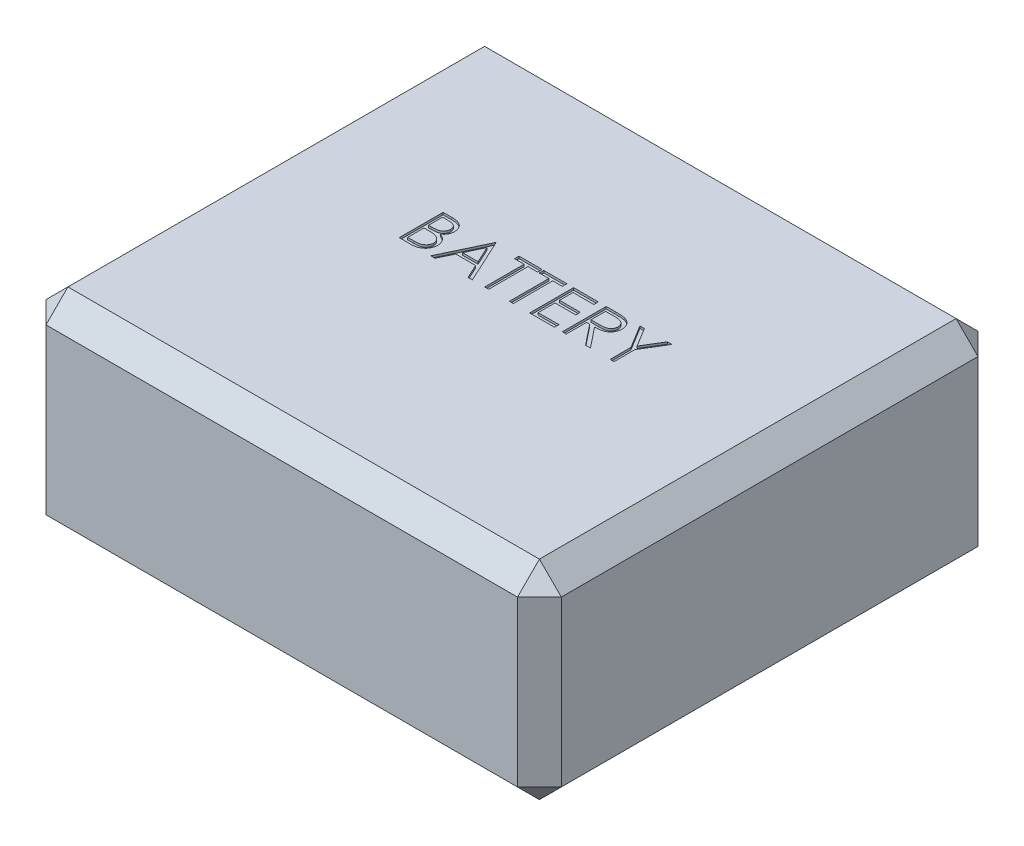
from build123d import *

# Parameters (mm, degrees)
SKETCH1_W           = 235
SKETCH1_H           = 210
BOSS_EXTRUDE1_DEPTH = 95
CUT_EXTRUDE1_DEPTH  = 1
CHAMFER1_SIZE       = 10


with BuildPart() as part:
    # Sketch1 → Boss-Extrude1 (new body)
    with BuildSketch(Plane(origin=(0, 0, 0), x_dir=(1, 0, 0), z_dir=(0, 1, 0))):
        with Locations((117.5, 105)):
            Rectangle(SKETCH1_W, SKETCH1_H)
    extrude(amount=BOSS_EXTRUDE1_DEPTH)

    # Sketch2 → Cut-Extrude1 (cut)
    with BuildSketch(Plane(origin=(0, 95, 0), x_dir=(1, 0, 0), z_dir=(0, 1, 0))):
        with BuildLine():
            Line((66.08974359, 125), (69.991987179, 125))
            add(Edge.make_bspline(
                [(69.991987179, 125), (70.183007055, 124.998995712), (70.553251114, 124.997049152), (71.091647924, 124.966859831), (71.595926842, 124.925696003), (72.066234113, 124.860381188), (72.502352412, 124.781571033), (72.905596054, 124.686132084), (73.274682752, 124.571694292), (73.71532696, 124.389715542), (74.217730737, 124.119297437), (74.761721552, 123.719705636), (75.226888634, 123.230948704), (75.627953304, 122.679619244), (75.946816845, 122.07312912), (76.177498544, 121.425933755), (76.323543546, 120.746380945), (76.33856317, 120.279848499), (76.346153846, 120.044070513)],
                knots=[0, 0, 0, 0, 1.001505555, 1.941167018, 2.826882275, 3.653841531, 4.429895133, 5.150066043, 5.825578002, 6.45369114, 7.647487171, 8.808567382, 9.977351308, 11.170798116, 12.373658725, 13.556498008, 14.765093433, 16, 16, 16, 16], degree=3))
            add(Edge.make_bspline(
                [(76.346153846, 120.044070513), (76.339906884, 119.823198766), (76.327631013, 119.389164955), (76.210243817, 118.754341473), (76.026468569, 118.150048794), (75.771010002, 117.578492306), (75.438998595, 117.052585945), (75.045522489, 116.568087282), (74.570797903, 116.145509813), (74.215122246, 115.909264656), (74.034455128, 115.789262821)],
                knots=[0, 0, 0, 0, 1.044552857, 2.05264487, 3.044412934, 4.028983338, 5.005914585, 5.980388656, 6.974128949, 8, 8, 8, 8], degree=3))
            add(Edge.make_bspline(
                [(74.034455128, 115.789262821), (74.261657572, 115.702034255), (74.696352128, 115.535144401), (75.294557913, 115.240084607), (75.809957028, 114.919158262), (76.246512148, 114.568690547), (76.619870176, 114.190925914), (76.945886985, 113.780325261), (77.224066266, 113.331532359), (77.462425829, 112.849226443), (77.64841872, 112.338332338), (77.787709602, 111.803642189), (77.867523598, 111.247073302), (77.878881548, 110.868299705), (77.884615385, 110.677083333)],
                knots=[0, 0, 0, 0, 1.27268992, 2.434971085, 3.483601985, 4.442670788, 5.356604649, 6.2567628, 7.179492994, 8.113709626, 9.066344395, 10.018646069, 10.999752585, 12, 12, 12, 12], degree=3))
            add(Edge.make_bspline(
                [(77.884615385, 110.677083333), (77.879033407, 110.481844064), (77.868050711, 110.097705332), (77.7870223, 109.533390277), (77.649827403, 108.994104868), (77.460849424, 108.476360967), (77.214207626, 107.981160199), (76.91404783, 107.507941547), (76.556153181, 107.061459658), (76.15579393, 106.63675324), (75.702867384, 106.25488017), (75.214205927, 105.914790417), (74.683655528, 105.635098634), (74.119929848, 105.40014994), (73.516705184, 105.220680234), (72.876690285, 105.095122669), (72.200437132, 105.010522457), (71.736381411, 105.003567001), (71.498397436, 105)],
                knots=[0, 0, 0, 0, 0.978564426, 1.925352924, 2.850884081, 3.763762016, 4.682927383, 5.618979971, 6.567305752, 7.547517671, 8.540179244, 9.531824382, 10.526200242, 11.540722885, 12.589160233, 13.674978461, 14.80764778, 16, 16, 16, 16], degree=3))
            Line((71.498397436, 105), (66.08974359, 105))
            Line((66.08974359, 105), (66.08974359, 125))
        make_face()
        with BuildLine():
            Line((67.884615385, 122.948717949), (67.884615385, 116.538461538))
            Line((67.884615385, 116.538461538), (69.090544872, 116.538461538))
            add(Edge.make_bspline(
                [(69.090544872, 116.538461538), (69.266823702, 116.540746813), (69.607430327, 116.545162428), (70.100686879, 116.557811097), (70.558544125, 116.593228488), (70.980211743, 116.6286357), (71.365025708, 116.686204772), (71.712133488, 116.754731189), (72.026982614, 116.827204933), (72.390065731, 116.950459143), (72.801911151, 117.132617287), (73.24095746, 117.415313494), (73.628011572, 117.752024083), (73.954852645, 118.140543865), (74.222346762, 118.568350641), (74.40813942, 119.028618529), (74.534123901, 119.509876427), (74.545504081, 119.840266443), (74.551282051, 120.008012821)],
                knots=[0, 0, 0, 0, 1.156816544, 2.235205308, 3.236616184, 4.169592532, 5.011045266, 5.787822928, 6.49130361, 7.128639758, 8.301311294, 9.436451833, 10.541879658, 11.654887649, 12.756523258, 13.837046038, 14.901820046, 16, 16, 16, 16], degree=3))
            add(Edge.make_bspline(
                [(74.551282051, 120.008012821), (74.548275307, 120.119017229), (74.542377251, 120.336764498), (74.494072665, 120.654189379), (74.411972239, 120.952725108), (74.306519135, 121.236462881), (74.159155199, 121.496530597), (73.985649695, 121.741920286), (73.776017179, 121.964275249), (73.537403964, 122.172100954), (73.263068976, 122.356355398), (72.95317588, 122.517731188), (72.603532011, 122.647678483), (72.220029982, 122.761485069), (71.796766625, 122.841418176), (71.33862632, 122.908008963), (70.841856497, 122.941910346), (70.498170197, 122.946398134), (70.320512821, 122.948717949)],
                knots=[0, 0, 0, 0, 0.91205012, 1.789085906, 2.630437955, 3.453916878, 4.269457761, 5.079663411, 5.91843418, 6.774407191, 7.675494373, 8.627863946, 9.638891023, 10.736472738, 11.911756761, 13.175263542, 14.539845004, 16, 16, 16, 16], degree=3))
            Line((70.320512821, 122.948717949), (67.884615385, 122.948717949))
        make_face(mode=Mode.SUBTRACT)
        with BuildLine():
            Line((67.884615385, 114.487179487), (67.884615385, 107.051282051))
            Line((67.884615385, 107.051282051), (70.440705128, 107.051282051))
            add(Edge.make_bspline(
                [(70.440705128, 107.051282051), (70.623670419, 107.053474894), (70.976311897, 107.057701308), (71.485461783, 107.071498763), (71.957365233, 107.102883195), (72.389868866, 107.15228805), (72.787642881, 107.205879188), (73.14591547, 107.277943651), (73.467590861, 107.36050914), (73.840586905, 107.488132981), (74.260606953, 107.686398529), (74.713240418, 107.985336966), (75.11567595, 108.341470153), (75.457420288, 108.753646805), (75.737494509, 109.201825816), (75.941239966, 109.676942102), (76.066902005, 110.171145116), (76.082114401, 110.508097759), (76.08974359, 110.677083333)],
                knots=[0, 0, 0, 0, 1.160039823, 2.235823828, 3.228722157, 4.157150951, 4.99529583, 5.772374946, 6.472645482, 7.099169577, 8.269452708, 9.405989375, 10.527446681, 11.663510218, 12.788923519, 13.866172445, 14.929861265, 16, 16, 16, 16], degree=3))
            add(Edge.make_bspline(
                [(76.08974359, 110.677083333), (76.088165851, 110.782759565), (76.085035822, 110.992407461), (76.037832308, 111.300497856), (75.969181623, 111.598931418), (75.880430572, 111.888518506), (75.751176475, 112.164023514), (75.600281932, 112.430895283), (75.423359637, 112.689486594), (75.147678689, 113.016413756), (74.74669592, 113.393082402), (74.176942918, 113.761868129), (73.529101215, 114.059284169), (73.059229827, 114.185566891), (72.81650641, 114.250801282)],
                knots=[0, 0, 0, 0, 0.723448775, 1.435228256, 2.130040452, 2.821711965, 3.505591119, 4.210454504, 4.921174351, 5.648778258, 7.137944449, 8.670945889, 10.280296675, 12, 12, 12, 12], degree=3))
            add(Edge.make_bspline(
                [(72.81650641, 114.250801282), (72.719197291, 114.270544619), (72.508211049, 114.313352246), (72.164167732, 114.358539122), (71.771391339, 114.398796607), (71.328974897, 114.428574651), (70.836358662, 114.4593549), (70.292490556, 114.471325306), (69.699591615, 114.485606793), (69.28820663, 114.486641845), (69.074519231, 114.487179487)],
                knots=[0, 0, 0, 0, 0.634451884, 1.375622551, 2.216452059, 3.157844607, 4.20941857, 5.370758133, 6.634282058, 8, 8, 8, 8], degree=3))
            Line((69.074519231, 114.487179487), (67.884615385, 114.487179487))
        make_face(mode=Mode.SUBTRACT)
        Polygon((90.192307692, 125), (99.423076923, 105), (97.471955128, 105), (94.515224359, 111.41025641), (85.448717949, 111.41025641), (82.411858974, 105), (80.448717949, 105), (89.935897436, 125), align=None)
        Polygon((90.044070513, 121.09775641), (86.426282051, 113.461538462), (93.569711538, 113.461538462), align=None, mode=Mode.SUBTRACT)
        Polygon((100.705128205, 122.948717949), (100.705128205, 125), (111.217948718, 125), (111.217948718, 122.948717949), (106.858974359, 122.948717949), (106.858974359, 105), (105.064102564, 105), (105.064102564, 122.948717949), align=None)
        Polygon((111.987179487, 122.948717949), (111.987179487, 125), (122.5, 125), (122.5, 122.948717949), (118.141025641, 122.948717949), (118.141025641, 105), (116.346153846, 105), (116.346153846, 122.948717949), align=None)
        Polygon((125.576923077, 125), (136.858974359, 125), (136.858974359, 122.948717949), (127.371794872, 122.948717949), (127.371794872, 116.794871795), (136.858974359, 116.794871795), (136.858974359, 114.743589744), (127.371794872, 114.743589744), (127.371794872, 107.051282051), (136.858974359, 107.051282051), (136.858974359, 105), (125.576923077, 105), align=None)
        with BuildLine():
            Line((140.448717949, 125), (144.451121795, 125))
            add(Edge.make_bspline(
                [(144.451121795, 125), (144.718213958, 124.999110937), (145.231060497, 124.997403838), (145.965764899, 124.987885193), (146.633348311, 124.96060316), (147.233461678, 124.93712554), (147.766093992, 124.894314447), (148.232878511, 124.853396464), (148.631665354, 124.799832688), (148.873070218, 124.750087414), (148.982371795, 124.727564103)],
                knots=[0, 0, 0, 0, 1.410062039, 2.707475311, 3.878576406, 4.937260626, 5.877586885, 6.699081471, 7.410979367, 8, 8, 8, 8], degree=3))
            add(Edge.make_bspline(
                [(148.982371795, 124.727564103), (149.128695361, 124.691411158), (149.418221015, 124.619876508), (149.835078536, 124.468678789), (150.232303244, 124.293709506), (150.608245097, 124.088202532), (150.961021047, 123.850632363), (151.294268537, 123.585100235), (151.609499757, 123.293059059), (151.893966215, 122.967145679), (152.162189367, 122.625222766), (152.38841009, 122.255487013), (152.583418546, 121.868849713), (152.738678643, 121.461378754), (152.863695634, 121.037025772), (152.951845573, 120.591946934), (153.004709503, 120.128169933), (153.010091534, 119.811839026), (153.012820513, 119.651442308)],
                knots=[0, 0, 0, 0, 1.027469482, 2.033020251, 3.019912614, 3.986113645, 4.951240523, 5.91722682, 6.890402269, 7.87763091, 8.8651537, 9.85103654, 10.82876324, 11.815024772, 12.821070561, 13.842952187, 14.906261191, 16, 16, 16, 16], degree=3))
            add(Edge.make_bspline(
                [(153.012820513, 119.651442308), (153.004426238, 119.384955996), (152.988046833, 118.864972179), (152.835331955, 118.110338571), (152.585180414, 117.40639963), (152.240475905, 116.754041699), (151.801507473, 116.165980869), (151.273937238, 115.649463981), (150.657470886, 115.217235909), (150.083589081, 114.917505597), (149.576650797, 114.725546119), (149.159317581, 114.590481211), (148.70407771, 114.486127124), (148.215292941, 114.392640657), (147.690929195, 114.322059546), (147.132243256, 114.27036472), (146.538836675, 114.23805587), (146.13118485, 114.233244414), (145.921474359, 114.230769231)],
                knots=[0, 0, 0, 0, 1.260483769, 2.459530307, 3.627416485, 4.787058657, 5.939039949, 7.08810263, 8.267026773, 9.491475466, 10.141966685, 10.831826277, 11.566392101, 12.351337768, 13.187381173, 14.07005841, 15.007169909, 16, 16, 16, 16], degree=3))
            Line((145.921474359, 114.230769231), (153.269230769, 105))
            Line((153.269230769, 105), (151.049679487, 105))
            Line((151.049679487, 105), (143.701923077, 114.230769231))
            Line((143.701923077, 114.230769231), (142.243589744, 114.230769231))
            Line((142.243589744, 114.230769231), (142.243589744, 105))
            Line((142.243589744, 105), (140.448717949, 105))
            Line((140.448717949, 105), (140.448717949, 125))
        make_face()
        with BuildLine():
            Line((142.243589744, 122.948717949), (142.243589744, 116.282051282))
            Line((142.243589744, 116.282051282), (145.905448718, 116.25400641))
            add(Edge.make_bspline(
                [(145.905448718, 116.25400641), (146.076420369, 116.253930772), (146.407812124, 116.253784164), (146.887244494, 116.276605743), (147.333645132, 116.302567561), (147.745306573, 116.342278107), (148.122412718, 116.39345566), (148.464775079, 116.457472713), (148.772952519, 116.532055928), (149.132372738, 116.64749379), (149.533724346, 116.830385323), (149.969904117, 117.096473887), (150.341346047, 117.431154567), (150.655162403, 117.813860031), (150.907330583, 118.234638595), (151.08511375, 118.688446419), (151.197927706, 119.163826979), (151.21123368, 119.490559024), (151.217948718, 119.655448718)],
                knots=[0, 0, 0, 0, 1.146690395, 2.22261258, 3.21895312, 4.145990853, 4.996080663, 5.770904154, 6.481378293, 7.121626537, 8.300444488, 9.431385265, 10.535395872, 11.636531494, 12.74115979, 13.810798291, 14.895190096, 16, 16, 16, 16], degree=3))
            add(Edge.make_bspline(
                [(151.217948718, 119.655448718), (151.211079455, 119.816286282), (151.197467081, 120.135007646), (151.086331261, 120.601612848), (150.898391939, 121.04199542), (150.645122008, 121.454363905), (150.336555408, 121.828682396), (149.974739336, 122.148951842), (149.569566792, 122.413234497), (149.19087423, 122.582116672), (148.852393016, 122.68565869), (148.558509244, 122.758522484), (148.226443657, 122.817062306), (147.854583894, 122.863965511), (147.444517432, 122.904279478), (146.994170854, 122.931432499), (146.50653211, 122.947511722), (146.168549646, 122.948306516), (145.993589744, 122.948717949)],
                knots=[0, 0, 0, 0, 1.101028733, 2.181837193, 3.264309656, 4.369019818, 5.486613113, 6.575447106, 7.666700264, 8.788928104, 9.402425223, 10.0903467, 10.862060571, 11.710948788, 12.657782767, 13.684531032, 14.801375019, 16, 16, 16, 16], degree=3))
            Line((145.993589744, 122.948717949), (142.243589744, 122.948717949))
        make_face(mode=Mode.SUBTRACT)
        Polygon((155.833333333, 125), (157.888621795, 125), (163.137019231, 116.414262821), (168.389423077, 125), (170.448717949, 125), (164.038461538, 114.507211538), (164.038461538, 105), (162.243589744, 105), (162.243589744, 114.507211538), align=None)
    extrude(amount=-CUT_EXTRUDE1_DEPTH, mode=Mode.SUBTRACT)

    # Chamfer1
    chamfer1_edges = [part.edges().sort_by_distance(p)[0] for p in [
        (235, 95, -105),
        (117.5, 95, -210),
        (0, 95, -105),
        (117.5, 0, -210),
        (235, 0, -105),
        (117.5, 0, 0),
        (0, 0, -105),
        (0, 47.5, -210),
        (235, 47.5, -210),
        (235, 47.5, 0),
        (0, 47.5, 0),
        (117.5, 95, 0),
    ]]
    chamfer(chamfer1_edges, length=CHAMFER1_SIZE)


solid = part.part
